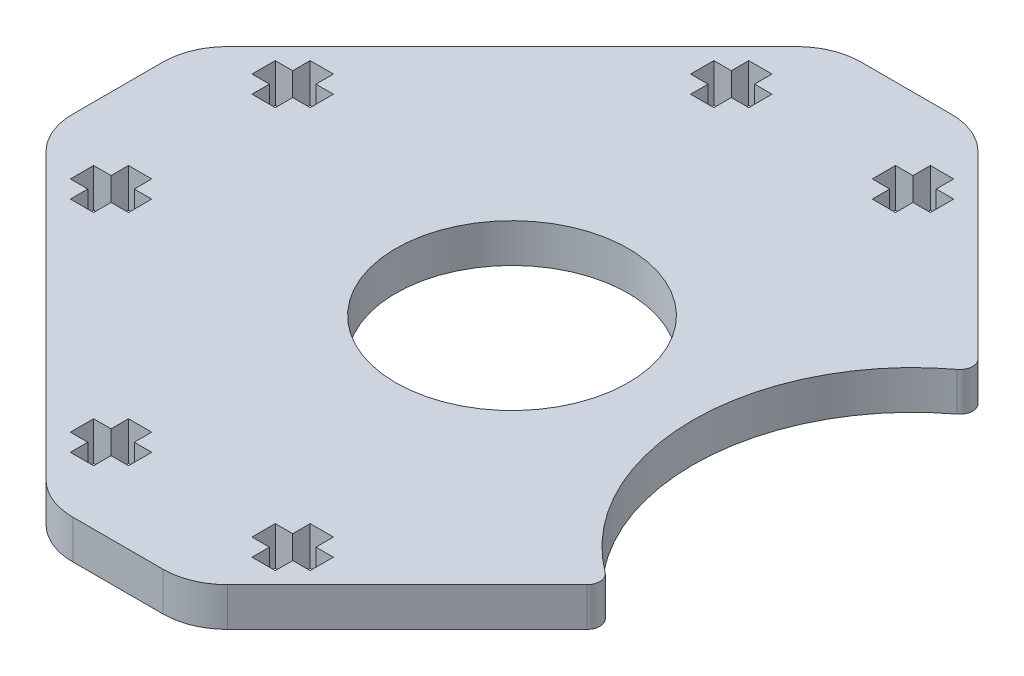
from build123d import *

# Parameters (mm, degrees)
SKETCH1_R           = 9
BOSS_EXTRUDE1_DEPTH = 3
CUT_EXTRUDE1_DEPTH  = 4
FILLET1_R           = 1


with BuildPart() as part:
    # Sketch1 → Boss-Extrude1 (new body)
    with BuildSketch(Plane(origin=(0, 0, 0), x_dir=(1, 0, 0), z_dir=(0, 1, 0))):
        with BuildLine():
            Line((3.491378029, 30.5), (-3.491378029, 30.5))
            ThreePointArc((-3.491378029, 30.5), (-5.40479519, 30.119397663), (-7.026911935, 29.035533906))
            Line((-7.026911935, 29.035533906), (-29.035533906, 7.026911935))
            ThreePointArc((-29.035533906, 7.026911935), (-30.119397663, 5.40479519), (-30.5, 3.491378029))
            Line((-30.5, 3.491378029), (-30.5, -3.491378029))
            ThreePointArc((-30.5, -3.491378029), (-30.119397663, -5.40479519), (-29.035533906, -7.026911935))
            Line((-29.035533906, -7.026911935), (-7.026911935, -29.035533906))
            ThreePointArc((-7.026911935, -29.035533906), (-5.40479519, -30.119397663), (-3.491378029, -30.5))
            Line((-3.491378029, -30.5), (3.491378029, -30.5))
            ThreePointArc((3.491378029, -30.5), (5.40479519, -30.119397663), (7.026911935, -29.035533906))
            Line((7.026911935, -29.035533906), (21.779928926, -14.282516914))
            ThreePointArc((21.779928926, -14.282516914), (14, 0), (21.779928926, 14.282516914))
            Line((21.779928926, 14.282516914), (7.026911935, 29.035533906))
            ThreePointArc((7.026911935, 29.035533906), (5.40479519, 30.119397663), (3.491378029, 30.5))
        make_face()
        Circle(SKETCH1_R, mode=Mode.SUBTRACT)
    extrude(amount=BOSS_EXTRUDE1_DEPTH)

    # Sketch4 → Cut-Extrude1 (cut, through all)
    with BuildSketch(Plane(origin=(0, 3, 0), x_dir=(1, 0, 0), z_dir=(0, 1, 0))):
        Polygon((-26.25, 7.929437252), (-26.25, 6.129437252), (-24.9, 6.129437252), (-24.9, 4.779437252), (-23.1, 4.779437252), (-23.1, 6.129437252), (-21.75, 6.129437252), (-21.75, 7.929437252), (-23.1, 7.929437252), (-23.1, 9.279437252), (-24.9, 9.279437252), (-24.9, 7.929437252), align=None)
        Polygon((-23.1, -4.779437252), (-24.9, -4.779437252), (-24.9, -6.129437252), (-26.25, -6.129437252), (-26.25, -7.929437252), (-24.9, -7.929437252), (-24.9, -9.279437252), (-23.1, -9.279437252), (-23.1, -7.929437252), (-21.75, -7.929437252), (-21.75, -6.129437252), (-23.1, -6.129437252), align=None)
        Polygon((7.929437252, 23.1), (9.279437252, 23.1), (9.279437252, 24.9), (7.929437252, 24.9), (7.929437252, 26.25), (6.129437252, 26.25), (6.129437252, 24.9), (4.779437252, 24.9), (4.779437252, 23.1), (6.129437252, 23.1), (6.129437252, 21.75), (7.929437252, 21.75), align=None)
        Polygon((26.25, -7.929437252), (26.25, -6.129437252), (24.9, -6.129437252), (24.9, -4.779437252), (23.1, -4.779437252), (23.1, -6.129437252), (21.75, -6.129437252), (21.75, -7.929437252), (23.1, -7.929437252), (23.1, -9.279437252), (24.9, -9.279437252), (24.9, -7.929437252), align=None)
        Polygon((-4.779437252, 24.9), (-6.129437252, 24.9), (-6.129437252, 26.25), (-7.929437252, 26.25), (-7.929437252, 24.9), (-9.279437252, 24.9), (-9.279437252, 23.1), (-7.929437252, 23.1), (-7.929437252, 21.75), (-6.129437252, 21.75), (-6.129437252, 23.1), (-4.779437252, 23.1), align=None)
        Polygon((26.25, 7.929437252), (24.9, 7.929437252), (24.9, 9.279437252), (23.1, 9.279437252), (23.1, 7.929437252), (21.75, 7.929437252), (21.75, 6.129437252), (23.1, 6.129437252), (23.1, 4.779437252), (24.9, 4.779437252), (24.9, 6.129437252), (26.25, 6.129437252), align=None)
        Polygon((-6.129437252, -26.25), (-6.129437252, -24.9), (-4.779437252, -24.9), (-4.779437252, -23.1), (-6.129437252, -23.1), (-6.129437252, -21.75), (-7.929437252, -21.75), (-7.929437252, -23.1), (-9.279437252, -23.1), (-9.279437252, -24.9), (-7.929437252, -24.9), (-7.929437252, -26.25), align=None)
        Polygon((7.929437252, -26.25), (7.929437252, -24.9), (9.279437252, -24.9), (9.279437252, -23.1), (7.929437252, -23.1), (7.929437252, -21.75), (6.129437252, -21.75), (6.129437252, -23.1), (4.779437252, -23.1), (4.779437252, -24.9), (6.129437252, -24.9), (6.129437252, -26.25), align=None)
    extrude(amount=-CUT_EXTRUDE1_DEPTH, mode=Mode.SUBTRACT)

    # Fillet1
    fillet1_edges = [part.edges().sort_by_distance(p)[0] for p in [
        (21.779928926, 1.5, -14.282516914),
        (21.779928926, 1.5, 14.282516914),
    ]]
    fillet(fillet1_edges, radius=FILLET1_R)


solid = part.part
